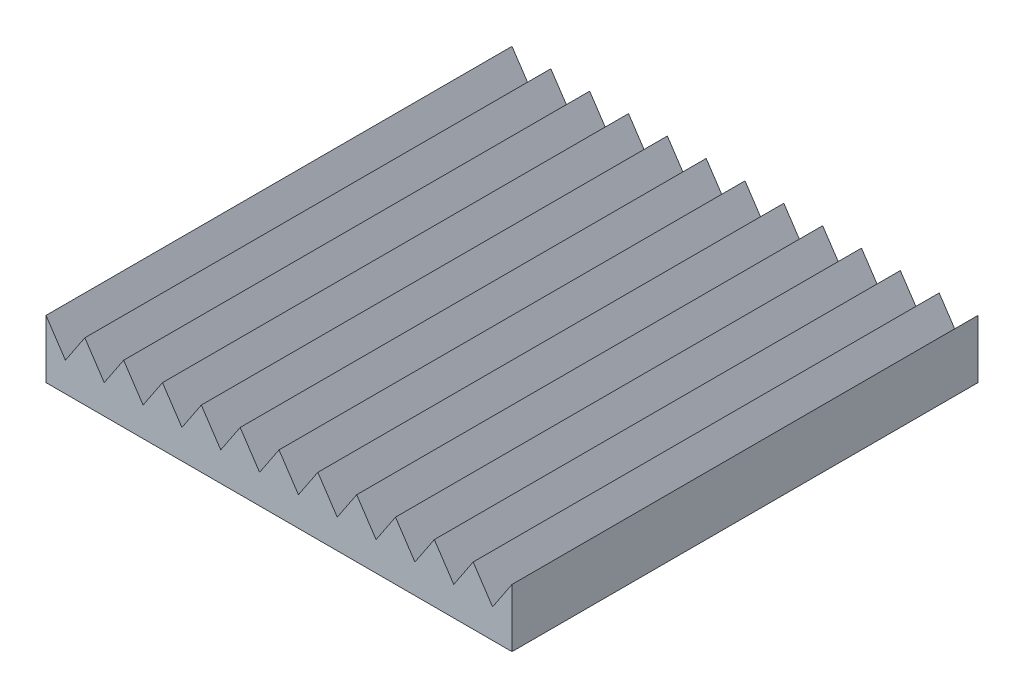
from build123d import *

# Parameters (mm, degrees)
SKETCH1_W           = 304.8
SKETCH1_H           = 304.8
BOSS_EXTRUDE1_DEPTH = 38.1
CUT_EXTRUDE1_DEPTH  = 305.8
LPATTERN1_COUNT     = 12
LPATTERN1_PITCH     = 25.4


with BuildPart() as part:
    # Sketch1 → Boss-Extrude1 (new body)
    with BuildSketch(Plane(origin=(0, 0, 0), x_dir=(1, 0, 0), z_dir=(0, 1, 0))):
        with Locations((152.4, -152.4)):
            Rectangle(SKETCH1_W, SKETCH1_H)
    extrude(amount=BOSS_EXTRUDE1_DEPTH)

    # Sketch2 → Cut-Extrude1 (cut, through all)
    with BuildSketch(Plane.XY.offset(304.8)):
        Polygon((0, 38.1), (12.7, 19.05), (25.4, 38.1), align=None)
    cut_extrude1 = extrude(amount=-CUT_EXTRUDE1_DEPTH, mode=Mode.SUBTRACT)

    # LPattern1: Cut-Extrude1 ×12
    with Locations(*[(i * LPATTERN1_PITCH, 0, 0) for i in range(1, LPATTERN1_COUNT)]):
        add(cut_extrude1, mode=Mode.SUBTRACT)


solid = part.part
